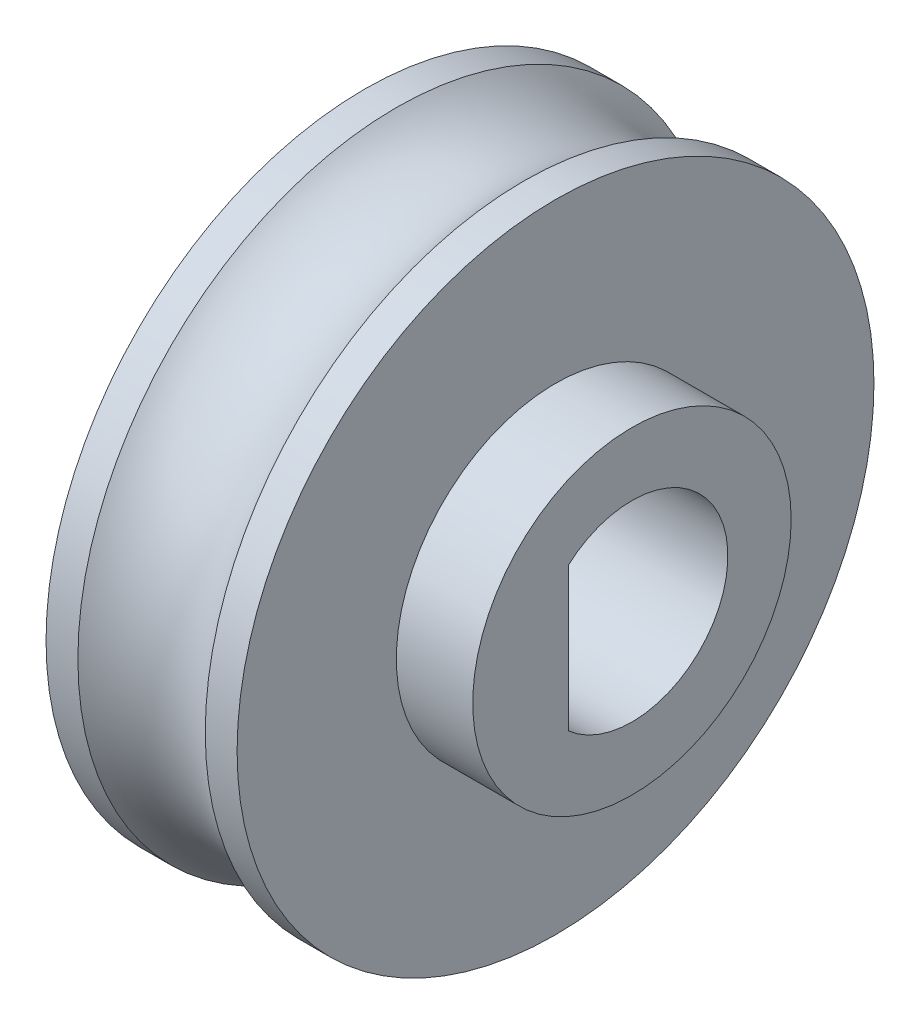
from build123d import *

# Parameters (mm, degrees)
SKETCH7_R               = 2.5
BOSS_EXTRUDE1_DEPTH     = 1.2
CUT_EXTRUDE1_DEPTH      = 2.2
CUT_EXTRUDE1_DEPTH_BACK = 4
SKETCH9_R               = 3.5
CUT_EXTRUDE2_DEPTH      = 1


with BuildPart() as part:
    # Sketch3 → Revolve1 (revolve)
    with BuildSketch(Plane.XY):
        with BuildLine():
            Line((-1.5, 0), (1.5, 0))
            Line((1.5, 0), (1.5, 5))
            Line((1.5, 5), (1, 5))
            ThreePointArc((1, 5), (0, 4.618033989), (-1, 5))
            Line((-1, 5), (-1.5, 5))
            Line((-1.5, 5), (-1.5, 0))
        make_face()
    revolve(axis=Axis((0, 0, 0), (1, 0, 0)))

    # Sketch7 → Boss-Extrude1 (add)
    with BuildSketch(Plane(origin=(1.5, 0, 0), x_dir=(0, 0, -1), z_dir=(1, 0, 0))):
        Circle(SKETCH7_R)
    extrude(amount=BOSS_EXTRUDE1_DEPTH)

    # Sketch5 → Cut-Extrude1 (cut, two sides)
    with BuildSketch(Plane(origin=(1.5, 0, 0), x_dir=(0, 0, -1), z_dir=(1, 0, 0))) as cut_extrude1_sk:
        with BuildLine():
            Line((-1, 1.125953933), (-1, -1.125953933))
            ThreePointArc((-1, -1.125953933), (1.505912434, 0), (-1, 1.125953933))
        make_face()
    extrude(amount=CUT_EXTRUDE1_DEPTH, mode=Mode.SUBTRACT)
    extrude(cut_extrude1_sk.sketch, amount=-CUT_EXTRUDE1_DEPTH_BACK, mode=Mode.SUBTRACT)

    # Sketch9 → Cut-Extrude2 (cut)
    with BuildSketch(Plane.ZY.offset(1.5)):
        Circle(SKETCH9_R)
    extrude(amount=-CUT_EXTRUDE2_DEPTH, mode=Mode.SUBTRACT)


solid = part.part
